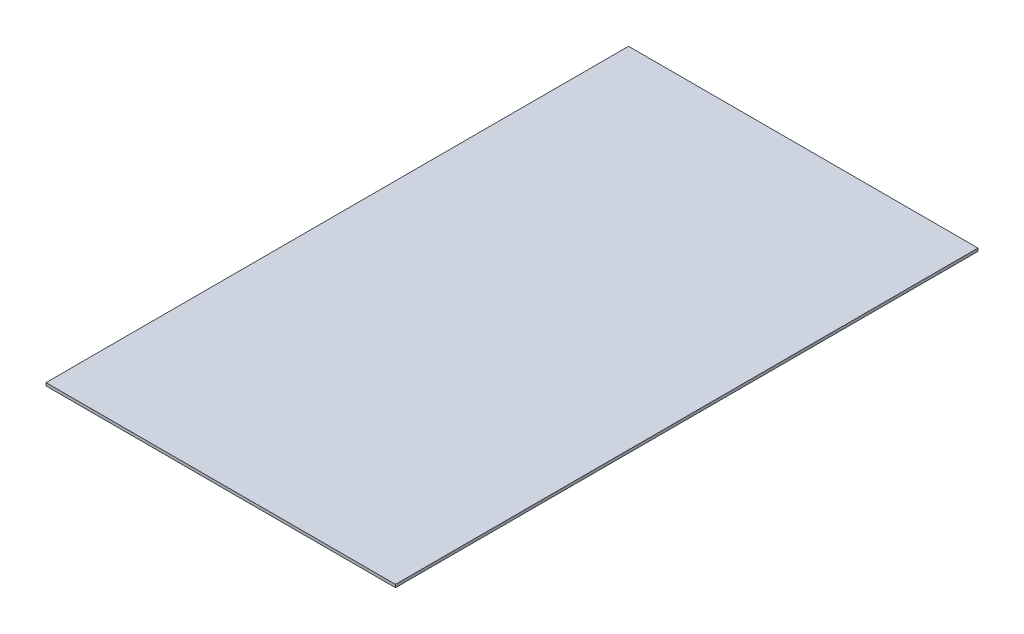
from build123d import *

# Parameters (mm, degrees)
SKETCH1_W           = 120
SKETCH1_H           = 200
BOSS_EXTRUDE1_DEPTH = 1


with BuildPart() as part:
    # Sketch1 → Boss-Extrude1 (new body)
    with BuildSketch(Plane(origin=(0, 0, 0), x_dir=(1, 0, 0), z_dir=(0, 1, 0))):
        Rectangle(SKETCH1_W, SKETCH1_H)
    extrude(amount=BOSS_EXTRUDE1_DEPTH)


solid = part.part
